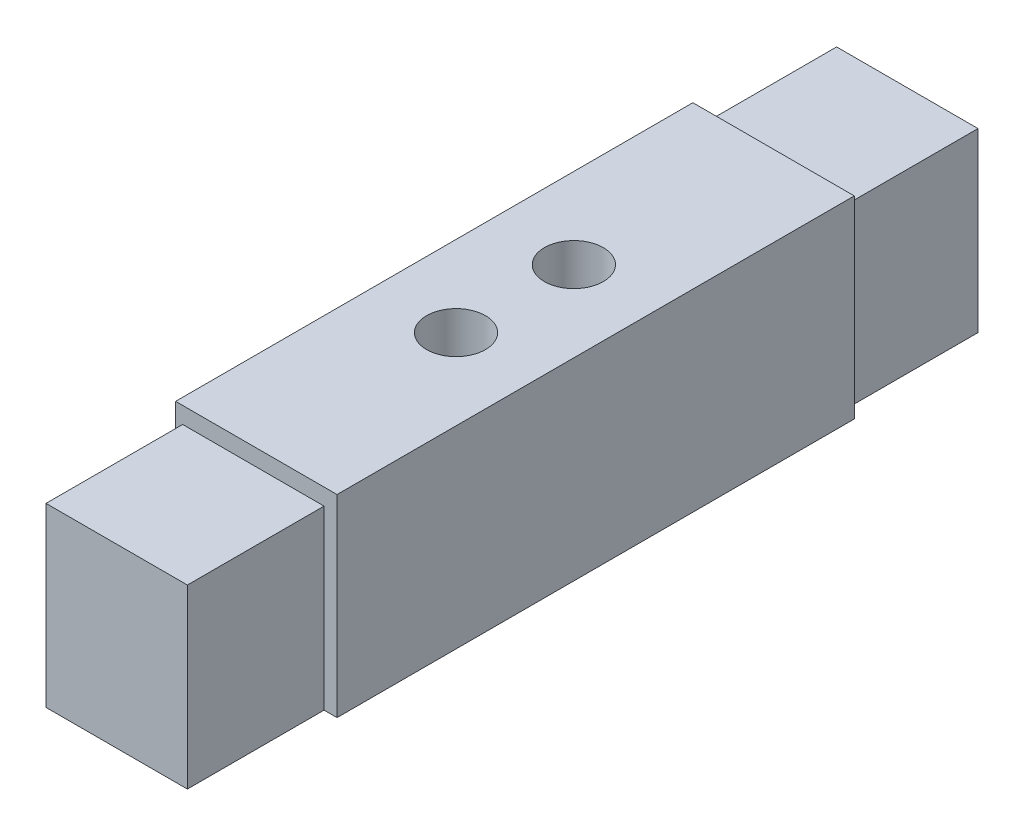
from build123d import *

# Parameters (mm, degrees)
SKETCH1_W           = 34.798
SKETCH1_H           = 41.656
BOSS_EXTRUDE2_DEPTH = 111.506
SKETCH2_W           = 30.48
SKETCH2_H           = 38.1
BOSS_EXTRUDE3_DEPTH = 29.464
SKETCH3_R           = 6.35
CUT_EXTRUDE2_DEPTH  = 12.7
SKETCH4_R           = 6.35
CUT_EXTRUDE3_DEPTH  = 12.7


with BuildPart() as part:
    # Sketch1 → Boss-Extrude2 (new body)
    with BuildSketch(Plane.XY):
        with Locations((17.399, 20.828)):
            Rectangle(SKETCH1_W, SKETCH1_H)
    extrude(amount=BOSS_EXTRUDE2_DEPTH)

    # Sketch2 → Boss-Extrude3 (add)
    with BuildSketch(Plane.XY.offset(111.506)):
        with Locations((16.764, 19.05)):
            Rectangle(SKETCH2_W, SKETCH2_H)
    boss_extrude3 = extrude(amount=BOSS_EXTRUDE3_DEPTH)

    # Mirror1: Boss-Extrude3 across plane
    add(boss_extrude3.mirror(Plane(origin=(0, 0, 55.753), x_dir=(1, 0, 0), z_dir=(0, 0, -1))))

    # Sketch3 → Cut-Extrude2 (cut)
    with BuildSketch(Plane.XZ):
        with Locations((16.764, 55.753)):
            Circle(SKETCH3_R)
    extrude(amount=-CUT_EXTRUDE2_DEPTH, mode=Mode.SUBTRACT)

    # Sketch4 → Cut-Extrude3 (cut)
    with BuildSketch(Plane(origin=(0, 41.656, 0), x_dir=(1, 0, 0), z_dir=(0, 1, 0))):
        with Locations((17.399, -43.053)):
            Circle(SKETCH4_R)
        with Locations((17.399, -68.453)):
            Circle(SKETCH4_R)
    extrude(amount=-CUT_EXTRUDE3_DEPTH, mode=Mode.SUBTRACT)


solid = part.part
